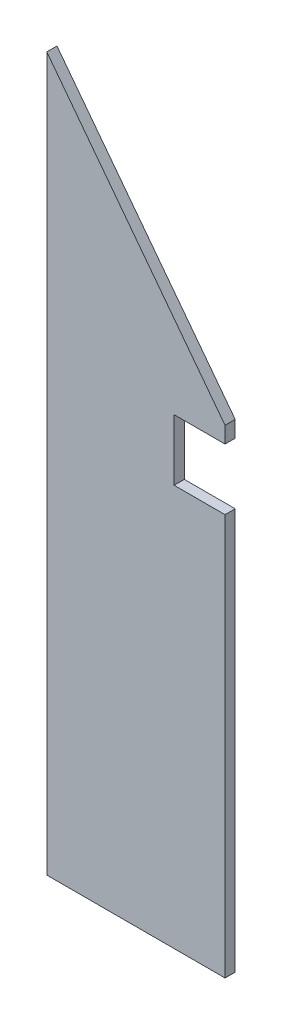
from build123d import *

# Parameters (mm, degrees)
BOSS_EXTRUDE1_DEPTH = 5


with BuildPart() as part:
    # Sketch1 → Boss-Extrude1 (new body)
    with BuildSketch(Plane.XY):
        Polygon((0, 350), (87.5, 235), (87.5, 227), (62.5, 227), (62.5, 197), (87.5, 197), (87.5, 0), (0, 0), align=None)
    extrude(amount=BOSS_EXTRUDE1_DEPTH)


solid = part.part
